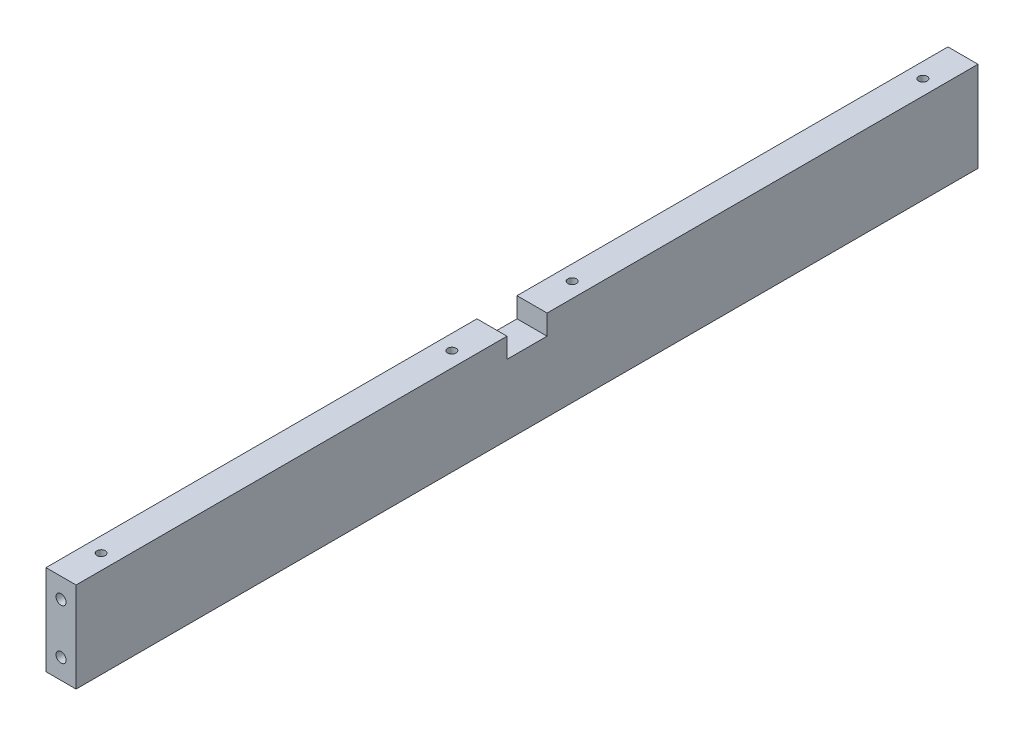
from build123d import *

# Parameters (mm, degrees)
ESQUISSE1_W                                   = 15
ESQUISSE1_H                                   = 45
BOSS_EXTRU_1_DEPTH                            = 450
TROU_POUR_TARAUDAGE_POUR_TROU_TARAUD_M6_D     = 5
TROU_POUR_TARAUDAGE_POUR_TROU_TARAUD_M6_DEPTH = 10
TROU_POUR_TARAUDAGE_POUR_TROU_TARAUD_M6_TIP   = 1.502151548
TROU_POUR_TARAUDAGE_POUR_TROU_TARAUD_2_D      = 5
TROU_POUR_TARAUDAGE_POUR_TROU_TARAUD_2_DEPTH  = 10
TROU_POUR_TARAUDAGE_POUR_TROU_TARAUD_2_TIP    = 1.502151548
ESQUISSE10_W                                  = 20
ESQUISSE10_H                                  = 10
ENL_V_MAT_EXTRU_1_DEPTH                       = 15
TROU_POUR_TARAUDAGE_POUR_TROU_TARAUD_M5_D     = 4.2
TROU_POUR_TARAUDAGE_POUR_TROU_TARAUD_M5_DEPTH = 25
TROU_POUR_TARAUDAGE_POUR_TROU_TARAUD_M5_TIP   = 1.2618073


with BuildPart() as part:
    # Esquisse1 → Boss.-Extru.1 (new body)
    with BuildSketch(Plane.XY):
        with Locations((-7.5, 22.5)):
            Rectangle(ESQUISSE1_W, ESQUISSE1_H)
    extrude(amount=BOSS_EXTRU_1_DEPTH)

    # Trou pour taraudage pour trou taraud_ M6
    with Locations(Plane.XY.offset(450)):
        with Locations((-7.5, 35), (-7.5, 10)):
            Hole(TROU_POUR_TARAUDAGE_POUR_TROU_TARAUD_M6_D / 2, depth=TROU_POUR_TARAUDAGE_POUR_TROU_TARAUD_M6_DEPTH)
            with Locations((0, 0, -(TROU_POUR_TARAUDAGE_POUR_TROU_TARAUD_M6_DEPTH + TROU_POUR_TARAUDAGE_POUR_TROU_TARAUD_M6_TIP / 2))):  # 118° drill point
                Cone(0, TROU_POUR_TARAUDAGE_POUR_TROU_TARAUD_M6_D / 2, TROU_POUR_TARAUDAGE_POUR_TROU_TARAUD_M6_TIP, mode=Mode.SUBTRACT)

    # Trou pour taraudage pour trou taraud 2
    with Locations(Plane(origin=(0, 0, 0), x_dir=(-1, 0, 0), z_dir=(0, 0, -1))):
        with Locations((7.5, 35), (7.5, 10)):
            Hole(TROU_POUR_TARAUDAGE_POUR_TROU_TARAUD_2_D / 2, depth=TROU_POUR_TARAUDAGE_POUR_TROU_TARAUD_2_DEPTH)
            with Locations((0, 0, -(TROU_POUR_TARAUDAGE_POUR_TROU_TARAUD_2_DEPTH + TROU_POUR_TARAUDAGE_POUR_TROU_TARAUD_2_TIP / 2))):  # 118° drill point
                Cone(0, TROU_POUR_TARAUDAGE_POUR_TROU_TARAUD_2_D / 2, TROU_POUR_TARAUDAGE_POUR_TROU_TARAUD_2_TIP, mode=Mode.SUBTRACT)

    # Esquisse10 → Enlèv. mat.-Extru.1 (cut)
    with BuildSketch(Plane(origin=(0, 0, 0), x_dir=(0, 0, -1), z_dir=(1, 0, 0))):
        with Locations((-225, 40)):
            Rectangle(ESQUISSE10_W, ESQUISSE10_H)
    extrude(amount=-ENL_V_MAT_EXTRU_1_DEPTH, mode=Mode.SUBTRACT)

    # Trou pour taraudage pour trou taraudé M51
    with Locations(Plane(origin=(0, 45, 0), x_dir=(1, 0, 0), z_dir=(0, 1, 0))):
        with Locations((-7.5, -430), (-7.5, -255), (-7.5, -195), (-7.5, -20)):
            Hole(TROU_POUR_TARAUDAGE_POUR_TROU_TARAUD_M5_D / 2, depth=TROU_POUR_TARAUDAGE_POUR_TROU_TARAUD_M5_DEPTH)
            with Locations((0, 0, -(TROU_POUR_TARAUDAGE_POUR_TROU_TARAUD_M5_DEPTH + TROU_POUR_TARAUDAGE_POUR_TROU_TARAUD_M5_TIP / 2))):  # 118° drill point
                Cone(0, TROU_POUR_TARAUDAGE_POUR_TROU_TARAUD_M5_D / 2, TROU_POUR_TARAUDAGE_POUR_TROU_TARAUD_M5_TIP, mode=Mode.SUBTRACT)


solid = part.part
